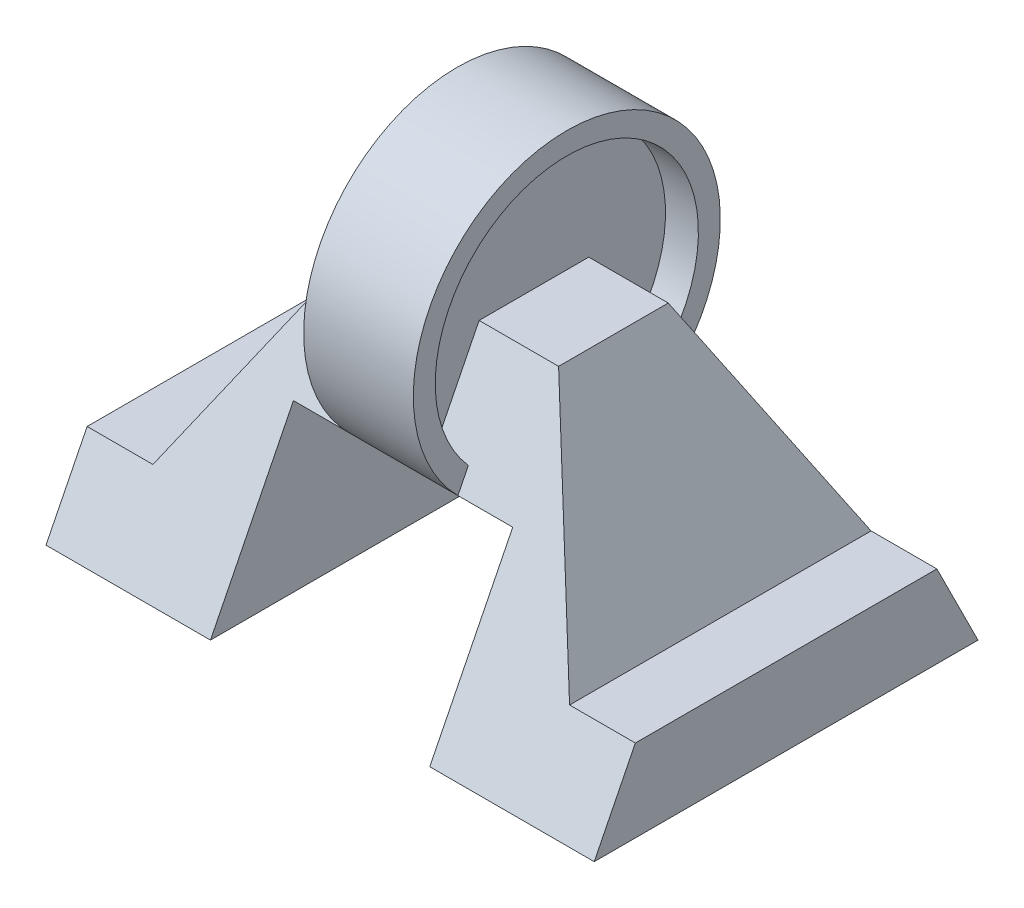
from build123d import *

# Parameters (mm, degrees)
BOSS_EXTRUDE1_DEPTH     = 50
BOSS_EXTRUDE2_DEPTH     = 10
BOSS_EXTRUDE3_DEPTH     = 4
CUT_EXTRUDE1_DEPTH      = 100.040395799
CUT_EXTRUDE1_DEPTH_BACK = 100.040395799
SKETCH3_W               = 40
SKETCH3_H               = 30.268164841


with BuildPart() as part:
    # Sketch2 → Boss-Extrude1 (new, symmetric)
    with BuildSketch(Plane(origin=(0, 0, 0), x_dir=(0, 0, -1), z_dir=(1, 0, 0))):
        Polygon((-35, 0), (0, 0), (35, 0), (10, 50), (-10, 50), align=None)
    extrude(amount=BOSS_EXTRUDE1_DEPTH, both=True)

    # Sketch2_5 → Boss-Extrude2 (add, symmetric)
    with BuildSketch(Plane(origin=(0, 0, 0), x_dir=(0, 0, -1), z_dir=(1, 0, 0))):
        with BuildLine():
            ThreePointArc((19.865917579, 30.268164841), (0, 78), (-19.865917579, 30.268164841))
            Line((-19.865917579, 30.268164841), (-13.662162394, 30.268164841))
            ThreePointArc((-13.662162394, 30.268164841), (0, 74), (13.662162394, 30.268164841))
            Line((13.662162394, 30.268164841), (19.865917579, 30.268164841))
        make_face()
    extrude(amount=BOSS_EXTRUDE2_DEPTH, both=True)

    # Sketch2_6 → Boss-Extrude3 (add, symmetric)
    with BuildSketch(Plane(origin=(0, 0, 0), x_dir=(0, 0, -1), z_dir=(1, 0, 0))):
        with BuildLine():
            ThreePointArc((17.959919678, 34.080160643), (0, 74), (-17.959919678, 34.080160643))
            Line((-17.959919678, 34.080160643), (-10, 50))
            Line((-10, 50), (10, 50))
            Line((10, 50), (17.959919678, 34.080160643))
        make_face()
    extrude(amount=BOSS_EXTRUDE3_DEPTH, both=True)

    # Sketch3 → Cut-Extrude1 (cut, two sides: drawn at the far end of the back side and taken through both)
    with BuildSketch(Plane.XY.offset(-CUT_EXTRUDE1_DEPTH_BACK)):
        with Locations((0, 15.134082421)):
            Rectangle(SKETCH3_W, SKETCH3_H)
        Polygon((50, 50), (18.5, 50), (38, 15), (50, 15), align=None)
        Polygon((-38, 15), (-18.5, 50), (-50, 50), (-50, 15), align=None)
    extrude(amount=CUT_EXTRUDE1_DEPTH + CUT_EXTRUDE1_DEPTH_BACK, mode=Mode.SUBTRACT)


solid = part.part
